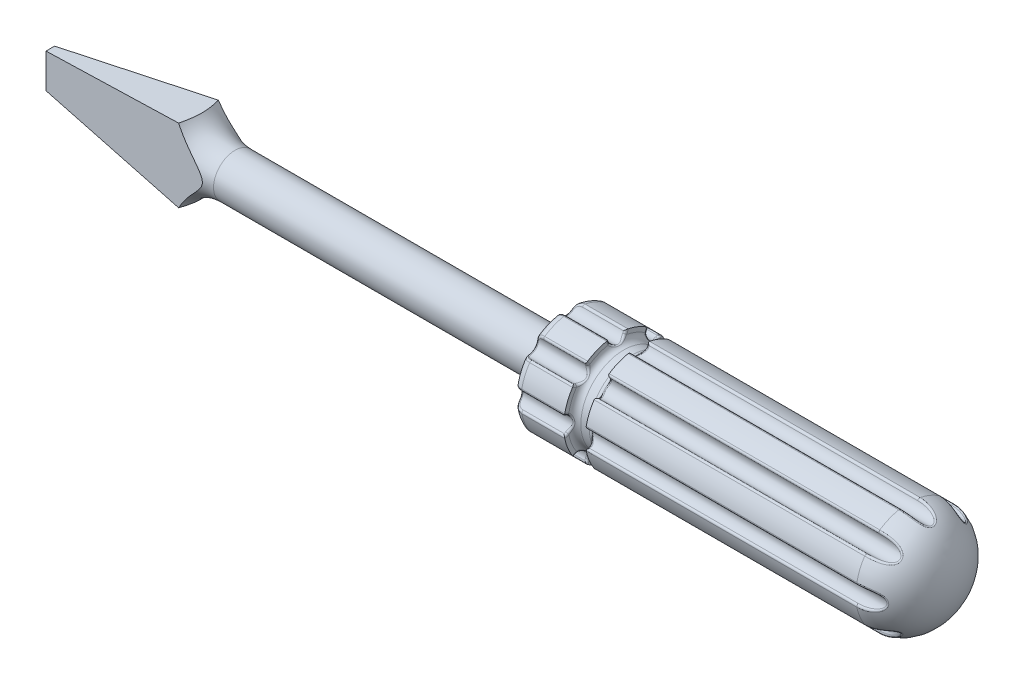
from build123d import *

# Parameters (mm, degrees)
SKETCH2_R                = 2.5
BOSS_EXTRUDE1_DEPTH      = 43.5
SKETCH3_W                = 16.5
SKETCH3_H                = 16.5
BOSS_EXTRUDE2_DEPTH      = 8.25
FILLET1_R                = 5
CUT_EXTRUDE4_REACH       = 18.5
CUT_EXTRUDE6_DEPTH       = 7.2500001
CUT_EXTRUDE6_DEPTH_BACK  = 7.2500001
SKETCH9_R                = 1
CUT_EXTRUDE7_DEPTH       = 46.0000001
FILLET2_R                = 0.25
CIRPATTERN1_COUNT        = 8
FILLET2_OF_CIRPATTERN1_R = 0.25


with BuildPart() as part:
    # Sketch1 → Revolve1 (revolve)
    with BuildSketch(Plane.XY):
        with BuildLine():
            Line((0, 0), (0, 5.25))
            ThreePointArc((0, 5.25), (0.292893219, 5.957106781), (1, 6.25))
            Line((1, 6.25), (6, 6.25))
            Line((6, 6.25), (6, 5.75))
            ThreePointArc((6, 5.75), (6.219669914, 5.219669914), (6.75, 5))
            Line((6.75, 5), (7.75, 5))
            ThreePointArc((7.75, 5), (8.280330086, 5.219669914), (8.5, 5.75))
            Line((8.5, 5.75), (8.5, 6.25))
            Line((8.5, 6.25), (40, 6.25))
            add(Edge.make_bspline(
                [(45, 0), (45, 6.25), (40, 6.25)],
                knots=[4.71238898, 4.71238898, 4.71238898, 6.283185307, 6.283185307, 6.283185307], degree=2, weights=[1, 0.707106781, 1]))
            Line((45, 0), (0, 0))
        make_face()
    revolve(axis=Axis((0, 0, 0), (1, 0, 0)))

    # Sketch2 → Boss-Extrude1 (add)
    with BuildSketch(Plane.ZY):
        Circle(SKETCH2_R)
    extrude(amount=BOSS_EXTRUDE1_DEPTH)

    # Sketch3 → Boss-Extrude2 (add, symmetric)
    with BuildSketch(Plane.XY):
        with Locations((-51.75, 0)):
            Rectangle(SKETCH3_W, SKETCH3_H)
    extrude(amount=BOSS_EXTRUDE2_DEPTH, both=True)

    # Fillet1
    fillet1_edges = [part.edges().sort_by_distance(p)[0] for p in [
        (-43.5, 0, -2.5),
    ]]
    fillet(fillet1_edges, radius=FILLET1_R)

    # Sketch4 → Cut-Extrude4 (cut, up to next)
    with BuildSketch(Plane.XY.offset(8.25), mode=Mode.PRIVATE) as cut_extrude4_sk1:
        Polygon((-60, 2), (-42.360343675, 4.322304812), (-42.360343675, 8.25), (-60, 8.25), align=None)
    cut_extrude4_tool1 = extrude(cut_extrude4_sk1.sketch, amount=-CUT_EXTRUDE4_REACH, mode=Mode.PRIVATE) & part.part
    add(cut_extrude4_tool1.solids().sort_by_distance((-51.850996, 5.661418, 8.25))[0], mode=Mode.SUBTRACT)
    # Sketch4 → Cut-Extrude4 (cut, up to next)
    with BuildSketch(Plane.XY.offset(8.25), mode=Mode.PRIVATE) as cut_extrude4_sk2:
        Polygon((-42.360343675, -4.322304812), (-42.360343675, -8.25), (-60, -8.25), (-60, -2), align=None)
    cut_extrude4_tool2 = extrude(cut_extrude4_sk2.sketch, amount=-CUT_EXTRUDE4_REACH, mode=Mode.PRIVATE) & part.part
    add(cut_extrude4_tool2.solids().sort_by_distance((-51.850996, -5.661418, 8.25))[0], mode=Mode.SUBTRACT)

    # Sketch7 → Cut-Extrude6 (cut, two sides)
    with BuildSketch(Plane(origin=(0, 0, 0), x_dir=(1, 0, 0), z_dir=(0, 1, 0))) as cut_extrude6_sk:
        Polygon((-60, 0.5), (-39.664066443, 2.637392745), (-39.664066443, 8.25), (-60, 8.25), align=None)
        Polygon((-60, -8.25), (-60, -0.5), (-39.664066443, -2.637392745), (-39.664066443, -8.25), align=None)
    extrude(amount=CUT_EXTRUDE6_DEPTH, mode=Mode.SUBTRACT)
    extrude(cut_extrude6_sk.sketch, amount=-CUT_EXTRUDE6_DEPTH_BACK, mode=Mode.SUBTRACT)

    # Sketch9 → Cut-Extrude7 (cut, through all)
    with BuildSketch(Plane.ZY):
        with Locations((0, 6.25)):
            Circle(SKETCH9_R)
    cut_extrude7 = extrude(amount=-CUT_EXTRUDE7_DEPTH, mode=Mode.SUBTRACT)

    # Fillet2
    fillet2_edges = [part.edges().sort_by_distance(p)[0] for p in [
        (24.25, 6.17, -0.996794864),
        (41.621259201, 5.841439826, -0.912731381),
        (24.25, 6.17, 0.996794864),
        (8.5, 5.919120245, 0.943672924),
        (8.406333657, 5.366632429, 0.468680849),
        (8.5, 5.919120245, -0.943672924),
        (6, 5.919120245, -0.943672924),
        (6.093666343, 5.366632429, -0.468680849),
        (6, 5.919120245, 0.943672924),
        (3.5, 6.17, 0.996794864),
        (0.148917123, 5.713078992, 0.843632478),
        (0.148917123, 5.713078992, -0.843632478),
        (3.5, 6.17, -0.996794864),
    ]]
    fillet(fillet2_edges, radius=FILLET2_R)

    # CirPattern1: Cut-Extrude7 ×8 about axis
    cirpattern1_axis = Axis((-43.5, 0, 0), (1, 0, 0))
    for i in range(1, CIRPATTERN1_COUNT):
        add(cut_extrude7.rotate(cirpattern1_axis, i * 360 / CIRPATTERN1_COUNT), mode=Mode.SUBTRACT)

    # Fillet2 of CirPattern1
    fillet2_of_cirpattern1_edges = [part.edges().sort_by_distance(p)[0] for p in [
        (24.25, 5.067689247, 3.658008432),
        (41.621259201, 4.775920262, 3.485123164),
        (24.25, 3.658008432, 5.067689247),
        (8.5, 3.51817254, 4.852727588),
        (8.406333657, 3.463374776, 4.12618959),
        (8.5, 4.852727588, 3.51817254),
        (6, 4.852727588, 3.51817254),
        (6.093666343, 4.12618959, 3.463374776),
        (6, 3.51817254, 4.852727588),
        (3.5, 3.658008432, 5.067689247),
        (0.148917123, 3.443218651, 4.636295143),
        (0.148917123, 4.636295143, 3.443218651),
        (3.5, 5.067689247, 3.658008432),
        (24.25, 0.996794864, 6.17),
        (41.621259201, 0.912731381, 5.841439826),
        (24.25, -0.996794864, 6.17),
        (8.5, -0.943672924, 5.919120245),
        (8.406333657, -0.468680849, 5.366632429),
        (8.5, 0.943672924, 5.919120245),
        (6, 0.943672924, 5.919120245),
        (6.093666343, 0.468680849, 5.366632429),
        (6, -0.943672924, 5.919120245),
        (3.5, -0.996794864, 6.17),
        (0.148917123, -0.843632478, 5.713078992),
        (0.148917123, 0.843632478, 5.713078992),
        (3.5, 0.996794864, 6.17),
        (24.25, -3.658008432, 5.067689247),
        (41.621259201, -3.485123164, 4.775920262),
        (24.25, -5.067689247, 3.658008432),
        (8.5, -4.852727588, 3.51817254),
        (8.406333657, -4.12618959, 3.463374776),
        (8.5, -3.51817254, 4.852727588),
        (6, -3.51817254, 4.852727588),
        (6.093666343, -3.463374776, 4.12618959),
        (6, -4.852727588, 3.51817254),
        (3.5, -5.067689247, 3.658008432),
        (0.148917123, -4.636295143, 3.443218651),
        (0.148917123, -3.443218651, 4.636295143),
        (3.5, -3.658008432, 5.067689247),
        (24.25, -6.17, 0.996794864),
        (41.621259201, -5.841439826, 0.912731381),
        (24.25, -6.17, -0.996794864),
        (8.5, -5.919120245, -0.943672924),
        (8.406333657, -5.366632429, -0.468680849),
        (8.5, -5.919120245, 0.943672924),
        (6, -5.919120245, 0.943672924),
        (6.093666343, -5.366632429, 0.468680849),
        (6, -5.919120245, -0.943672924),
        (3.5, -6.17, -0.996794864),
        (0.148917123, -5.713078992, -0.843632478),
        (0.148917123, -5.713078992, 0.843632478),
        (3.5, -6.17, 0.996794864),
        (24.25, -5.067689247, -3.658008432),
        (41.621259201, -4.775920262, -3.485123164),
        (24.25, -3.658008432, -5.067689247),
        (8.5, -3.51817254, -4.852727588),
        (8.406333657, -3.463374776, -4.12618959),
        (8.5, -4.852727588, -3.51817254),
        (6, -4.852727588, -3.51817254),
        (6.093666343, -4.12618959, -3.463374776),
        (6, -3.51817254, -4.852727588),
        (3.5, -3.658008432, -5.067689247),
        (0.148917123, -3.443218651, -4.636295143),
        (0.148917123, -4.636295143, -3.443218651),
        (3.5, -5.067689247, -3.658008432),
        (24.25, -0.996794864, -6.17),
        (41.621259201, -0.912731381, -5.841439826),
        (24.25, 0.996794864, -6.17),
        (8.5, 0.943672924, -5.919120245),
        (8.406333657, 0.468680849, -5.366632429),
        (8.5, -0.943672924, -5.919120245),
        (6, -0.943672924, -5.919120245),
        (6.093666343, -0.468680849, -5.366632429),
        (6, 0.943672924, -5.919120245),
        (3.5, 0.996794864, -6.17),
        (0.148917123, 0.843632478, -5.713078992),
        (0.148917123, -0.843632478, -5.713078992),
        (3.5, -0.996794864, -6.17),
        (24.25, 3.658008432, -5.067689247),
        (41.621259201, 3.485123164, -4.775920262),
        (24.25, 5.067689247, -3.658008432),
        (8.5, 4.852727588, -3.51817254),
        (8.406333657, 4.12618959, -3.463374776),
        (8.5, 3.51817254, -4.852727588),
        (6, 3.51817254, -4.852727588),
        (6.093666343, 3.463374776, -4.12618959),
        (6, 4.852727588, -3.51817254),
        (3.5, 5.067689247, -3.658008432),
        (0.148917123, 4.636295143, -3.443218651),
        (0.148917123, 3.443218651, -4.636295143),
        (3.5, 3.658008432, -5.067689247),
    ]]
    fillet(fillet2_of_cirpattern1_edges, radius=FILLET2_OF_CIRPATTERN1_R)


solid = part.part
